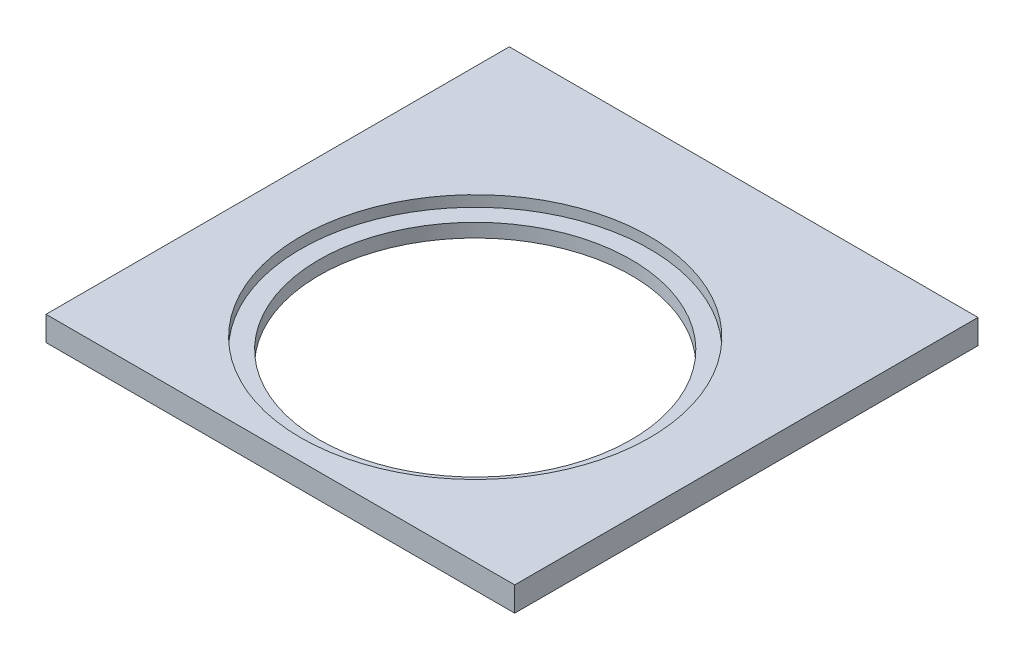
from build123d import *

# Parameters (mm, degrees)
SKETCH_1_W               = 344
SKETCH_1_H               = 340
EXTRUDE_1_DEPTH          = 18
SKETCH_2_R               = 114.5
CUT_EXTRUDE_1_DEPTH      = 1
CUT_EXTRUDE_1_DEPTH_BACK = 19
SKETCH_3_R               = 128
CUT_EXTRUDE_2_DEPTH      = 8


with BuildPart() as part:
    # Эскиз1 → Бобышка-Вытянуть1 (new body)
    with BuildSketch(Plane(origin=(0, 0, 0), x_dir=(1, 0, 0), z_dir=(0, 1, 0))):
        Rectangle(SKETCH_1_W, SKETCH_1_H)
    extrude(amount=EXTRUDE_1_DEPTH)

    # Эскиз2 → Вырез-Вытянуть1 (cut, two sides)
    with BuildSketch(Plane(origin=(0, 18, 0), x_dir=(1, 0, 0), z_dir=(0, 1, 0))) as cut_extrude_1_sk:
        with Locations((0, -27)):
            Circle(SKETCH_2_R)
    extrude(amount=CUT_EXTRUDE_1_DEPTH, mode=Mode.SUBTRACT)
    extrude(cut_extrude_1_sk.sketch, amount=-CUT_EXTRUDE_1_DEPTH_BACK, mode=Mode.SUBTRACT)

    # Эскиз3 → Вырез-Вытянуть2 (cut)
    with BuildSketch(Plane(origin=(0, 18, 0), x_dir=(1, 0, 0), z_dir=(0, 1, 0))):
        with Locations((0, -27)):
            Circle(SKETCH_3_R)
    extrude(amount=-CUT_EXTRUDE_2_DEPTH, mode=Mode.SUBTRACT)


solid = part.part
